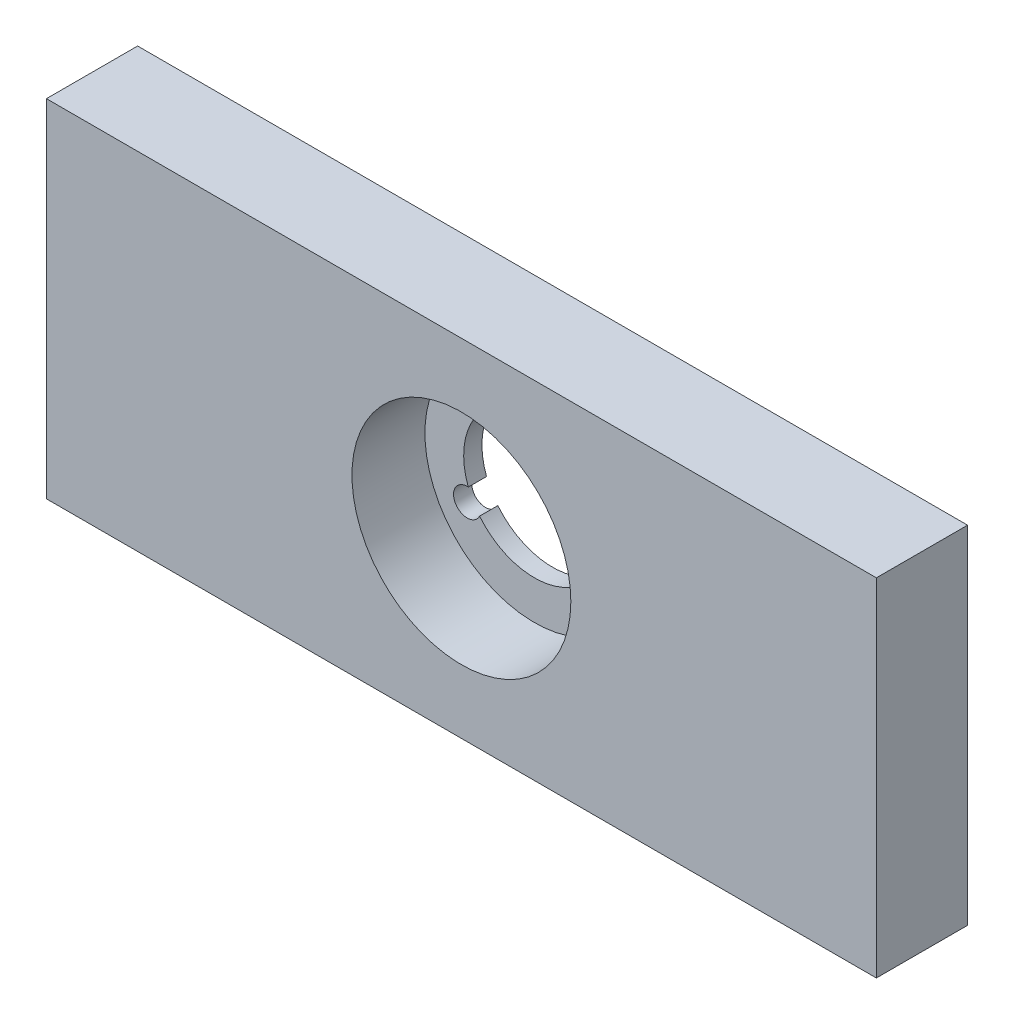
from build123d import *

# Parameters (mm, degrees)
ESQUISSE1_W      = 91
ESQUISSE1_H      = 38
EXTRUSION1_DEPTH = 10
ESQUISSE3_R      = 12
EXTRUSION3_DEPTH = 8


with BuildPart() as part:
    # Esquisse1 → Extrusion1 (new body)
    with BuildSketch(Plane.XY):
        with Locations((45.5, -19)):
            Rectangle(ESQUISSE1_W, ESQUISSE1_H)
        with BuildLine():
            ThreePointArc((44.263573917, -11.349264706), (38.788303121, -15.125), (38.256055836, -21.754591249))
            ThreePointArc((38.256055836, -21.754591249), (36.839745962, -24), (39.492481919, -23.896144045))
            ThreePointArc((39.492481919, -23.896144045), (45.5, -26.75), (51.507518081, -23.896144045))
            ThreePointArc((51.507518081, -23.896144045), (54.160254038, -24), (52.743944164, -21.754591249))
            ThreePointArc((52.743944164, -21.754591249), (52.211696879, -15.125), (46.736426083, -11.349264706))
            ThreePointArc((46.736426083, -11.349264706), (45.5, -9), (44.263573917, -11.349264706))
        make_face(mode=Mode.SUBTRACT)
    extrude(amount=EXTRUSION1_DEPTH)

    # Esquisse3 → Extrusion3 (cut)
    with BuildSketch(Plane.XY.offset(10)):
        with Locations((45.5, -19)):
            Circle(ESQUISSE3_R)
    extrude(amount=-EXTRUSION3_DEPTH, mode=Mode.SUBTRACT)


solid = part.part
